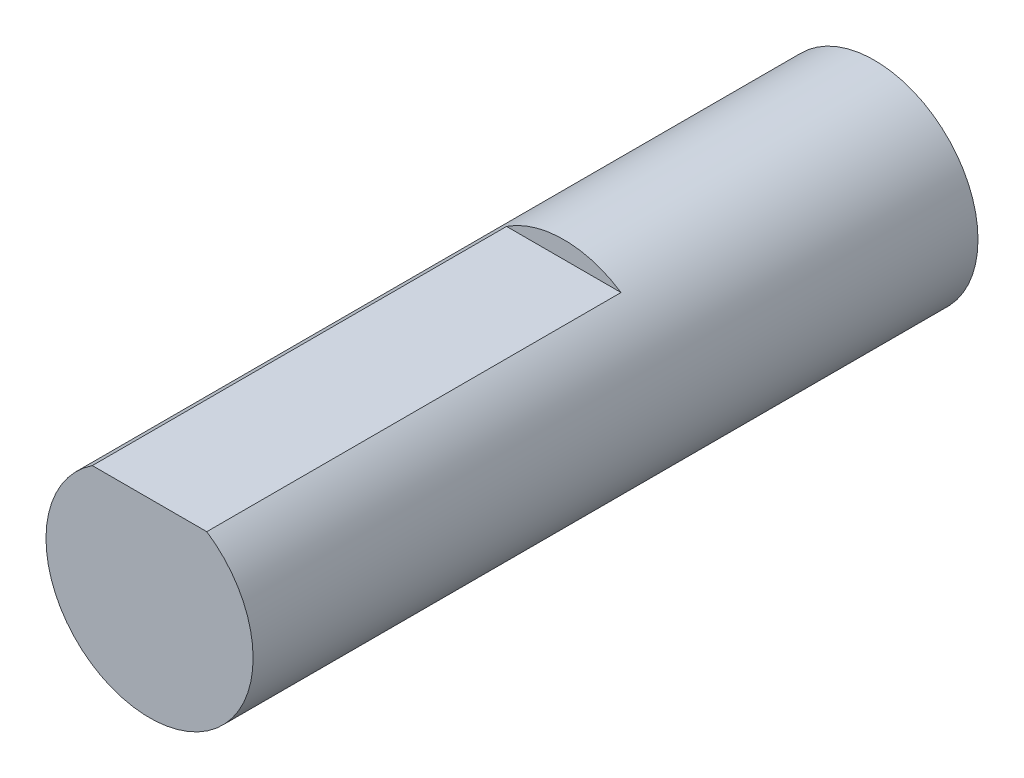
from build123d import *

# Parameters (mm, degrees)
BOSS_EXTRUDE1_DEPTH = 21
CUT_EXTRUDE1_START  = 21
CUT_EXTRUDE1_DEPTH  = 12


with BuildPart() as part:
    # Sketch1 → Boss-Extrude1 (new body)
    with BuildSketch(Plane.XY):
        with BuildLine():
            ThreePointArc((1.658312395, 2.5), (0, 3), (-1.658312395, 2.5))
            Line((-1.658312395, 2.5), (1.658312395, 2.5))
        make_face()
        with BuildLine():
            Line((1.658312395, 2.5), (-1.658312395, 2.5))
            ThreePointArc((-1.658312395, 2.5), (-1.418637165, -2.643382037), (3, 0))
            ThreePointArc((3, 0), (2.643382037, 1.418637165), (1.658312395, 2.5))
        make_face()
    extrude(amount=BOSS_EXTRUDE1_DEPTH)

    # Sketch1_3 → Cut-Extrude1 (cut)
    with BuildSketch(Plane.XY.offset(CUT_EXTRUDE1_START)):
        Polygon((-26.073564647, 2.5), (-1.658312395, 2.5), (1.658312395, 2.5), (26.073564647, 2.5), (26.073564647, 51.330504504), (-26.073564647, 51.330504504), align=None)
    extrude(amount=-CUT_EXTRUDE1_DEPTH, mode=Mode.SUBTRACT)


solid = part.part
